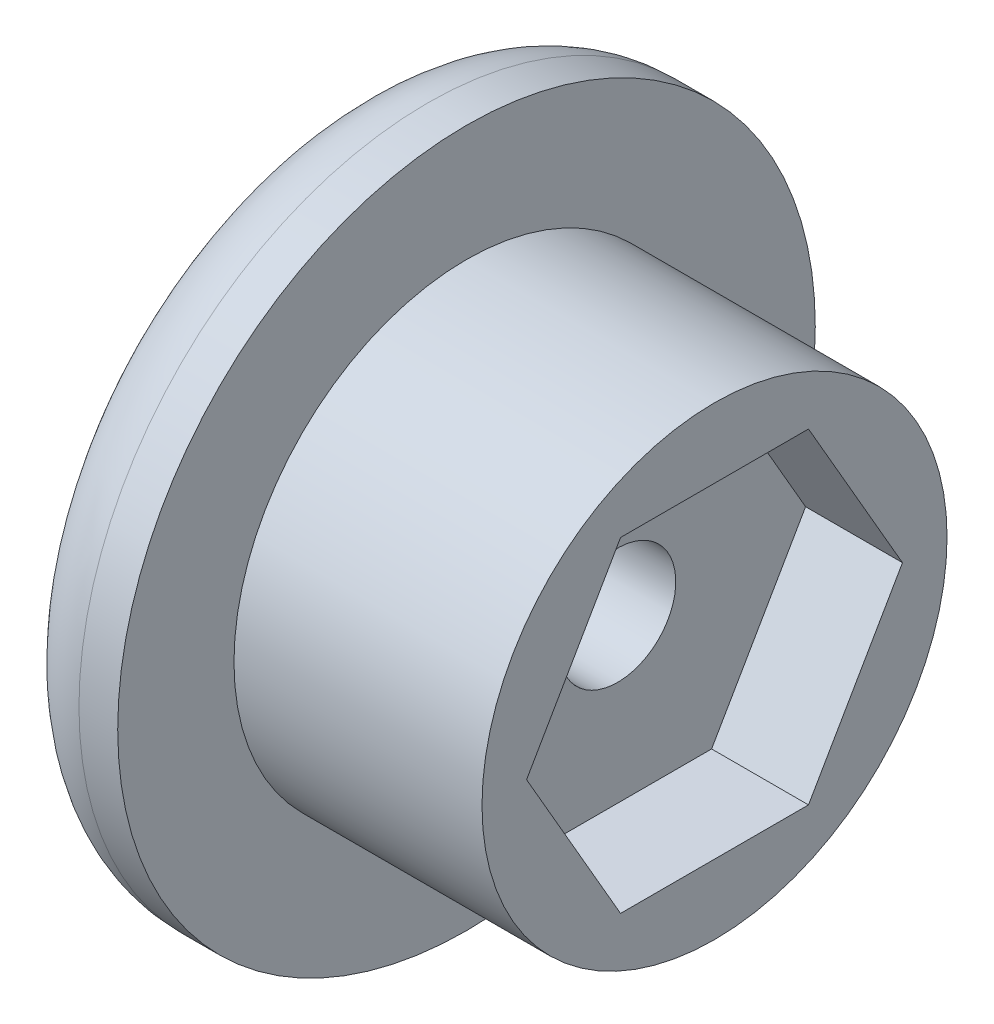
from build123d import *

# Parameters (mm, degrees)
CROQUIS1_R              = 6
SALIENTE_EXTRUIR1_DEPTH = 2.5
CROQUIS2_R              = 6
SALIENTE_EXTRUIR2_DEPTH = 5.5
CROQUIS3_R              = 1.5
CORTAR_EXTRUIR1_DEPTH   = 12.5
CROQUIS4_R              = 3
CORTAR_EXTRUIR2_DEPTH   = 3
CROQUIS5_R              = 9
CROQUIS5_R_2            = 3
SALIENTE_EXTRUIR3_DEPTH = 3
REDONDEO1_R             = 2


with BuildPart() as part:
    # Croquis1 → Saliente-Extruir1 (new body)
    with BuildSketch(Plane.ZY.offset(24.669607513)):
        with Locations((65.25, -8.936333162)):
            Circle(CROQUIS1_R)
        Polygon((67.674871131, -4.736333162), (62.825128869, -4.736333162), (60.400257739, -8.936333162), (62.825128869, -13.136333162), (67.674871131, -13.136333162), (70.099742261, -8.936333162), align=None, mode=Mode.SUBTRACT)
    extrude(amount=SALIENTE_EXTRUIR1_DEPTH)

    # Croquis2 → Saliente-Extruir2 (add)
    with BuildSketch(Plane.ZY.offset(27.169607513)):
        with Locations((65.25, -8.936333162)):
            Circle(CROQUIS2_R)
    extrude(amount=SALIENTE_EXTRUIR2_DEPTH)

    # Croquis3 → Cortar-Extruir1 (cut)
    with BuildSketch(Plane.ZY.offset(32.669607513)):
        with Locations((65.25, -8.936333162)):
            Circle(CROQUIS3_R)
    extrude(amount=-CORTAR_EXTRUIR1_DEPTH, mode=Mode.SUBTRACT)

    # Croquis4 → Cortar-Extruir2 (cut)
    with BuildSketch(Plane.ZY.offset(32.669607513)):
        with Locations((65.25, -8.936333162)):
            Circle(CROQUIS4_R)
    extrude(amount=-CORTAR_EXTRUIR2_DEPTH, mode=Mode.SUBTRACT)

    # Croquis5 → Saliente-Extruir3 (add)
    with BuildSketch(Plane.ZY.offset(31.069607513)):
        with Locations((65.25, -8.936333162)):
            Circle(CROQUIS5_R)
        with Locations((65.25, -8.936333162)):
            Circle(CROQUIS5_R_2, mode=Mode.SUBTRACT)
    extrude(amount=SALIENTE_EXTRUIR3_DEPTH)

    # Redondeo1
    redondeo1_edges = [part.edges().sort_by_distance(p)[0] for p in [
        (-34.069607513, -8.936333162, 56.25),
    ]]
    fillet(redondeo1_edges, radius=REDONDEO1_R)


solid = part.part
